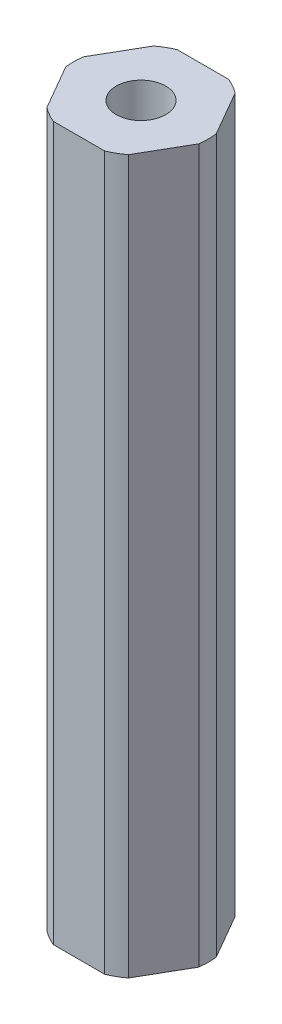
from build123d import *

# Parameters (mm, degrees)
SKETCH1_R           = 2.54
BOSS_EXTRUDE1_DEPTH = 73.025


with BuildPart() as part:
    # Sketch1 → Boss-Extrude1 (new body)
    with BuildSketch(Plane(origin=(0, 0, 0), x_dir=(1, 0, 0), z_dir=(0, 1, 0))):
        with BuildLine():
            Line((4.181770802, -5.456960506), (6.816751826, -0.893039494))
            ThreePointArc((6.816751826, -0.893039494), (6.875, 0), (6.816751826, 0.893039494))
            Line((6.816751826, 0.893039494), (4.181770802, 5.456960506))
            ThreePointArc((4.181770802, 5.456960506), (3.4375, 5.953924651), (2.634981025, 6.35))
            Line((2.634981025, 6.35), (-2.634981025, 6.35))
            ThreePointArc((-2.634981025, 6.35), (-3.4375, 5.953924651), (-4.181770802, 5.456960506))
            Line((-4.181770802, 5.456960506), (-6.816751826, 0.893039494))
            ThreePointArc((-6.816751826, 0.893039494), (-6.875, 0), (-6.816751826, -0.893039494))
            Line((-6.816751826, -0.893039494), (-4.181770802, -5.456960506))
            ThreePointArc((-4.181770802, -5.456960506), (-3.4375, -5.953924651), (-2.634981025, -6.35))
            Line((-2.634981025, -6.35), (2.634981025, -6.35))
            ThreePointArc((2.634981025, -6.35), (3.4375, -5.953924651), (4.181770802, -5.456960506))
        make_face()
        with Locations(Location((0, 0, 0), (0, 0, 270))):  # turned: the seam where the file's is
            Circle(SKETCH1_R, mode=Mode.SUBTRACT)
    extrude(amount=BOSS_EXTRUDE1_DEPTH)


solid = part.part
